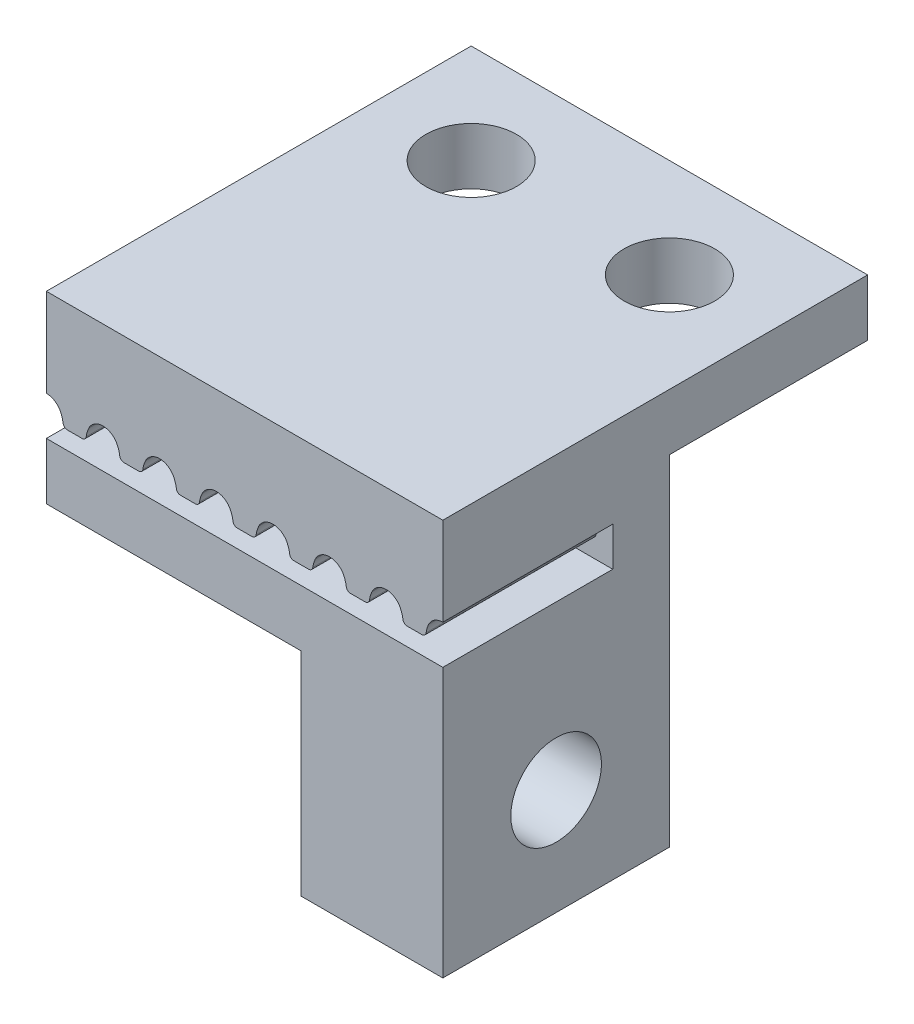
from build123d import *

# Parameters (mm, degrees)
SKETCH3_W           = 14
SKETCH3_H           = 6.5
BOSS_EXTRUDE2_DEPTH = 8
CUT_EXTRUDE1_START  = 2
CUT_EXTRUDE1_DEPTH  = 6
LPATTERN2_COUNT     = 7
LPATTERN2_PITCH     = 2
SKETCH4_W           = 14
SKETCH4_H           = 7
SKETCH4_R           = 1.6
BOSS_EXTRUDE3_DEPTH = 2
SKETCH5_W           = 5
SKETCH5_H           = 8
BOSS_EXTRUDE4_DEPTH = 7.5
SKETCH6_R           = 1.6
CUT_EXTRUDE2_DEPTH  = 7.5


with BuildPart() as part:
    # Sketch3 → Boss-Extrude2 (new body)
    with BuildSketch(Plane.XY):
        with Locations((7, 1.25)):
            Rectangle(SKETCH3_W, SKETCH3_H)
    extrude(amount=BOSS_EXTRUDE2_DEPTH)

    # Sketch1 → Cut-Extrude1 (cut)
    with BuildSketch(Plane.XY.offset(CUT_EXTRUDE1_START)):
        with BuildLine():
            Line((0.740175425, 0.63), (1.259824575, 0.63))
            ThreePointArc((1.259824575, 0.63), (1.358731646, 0.667228588), (1.408543109, 0.760434783))
            ThreePointArc((1.408543109, 0.760434783), (1.442388286, 0.918062154), (1.501123596, 1.068202247))
            ThreePointArc((1.501123596, 1.068202247), (1.705850588, 1.295639059), (2, 1.38))
            Line((2, 1.38), (2, 0))
            Line((2, 0), (0, 0))
            Line((0, 0), (0, 1.38))
            ThreePointArc((0, 1.38), (0.294149412, 1.295639059), (0.498876404, 1.068202247))
            ThreePointArc((0.498876404, 1.068202247), (0.557611714, 0.918062154), (0.591456891, 0.760434783))
            ThreePointArc((0.591456891, 0.760434783), (0.641268354, 0.667228588), (0.740175425, 0.63))
        make_face()
    cut_extrude1 = extrude(amount=CUT_EXTRUDE1_DEPTH, mode=Mode.SUBTRACT)

    # LPattern2: Cut-Extrude1 ×7
    with Locations(*[(i * LPATTERN2_PITCH, 0, 0) for i in range(1, LPATTERN2_COUNT)]):
        add(cut_extrude1, mode=Mode.SUBTRACT)

    # Sketch4 → Boss-Extrude3 (add)
    with BuildSketch(Plane(origin=(0, 4.5, 0), x_dir=(-1, 0, 0), z_dir=(0, 1, 0))):
        with Locations((-7, -3.5)):
            Rectangle(SKETCH4_W, SKETCH4_H)
        with Locations((-10.5, -3.5)):
            Circle(SKETCH4_R, mode=Mode.SUBTRACT)
        with Locations((-3.5, -3.5)):
            Circle(SKETCH4_R, mode=Mode.SUBTRACT)
    extrude(amount=-BOSS_EXTRUDE3_DEPTH)

    # Sketch5 → Boss-Extrude4 (add)
    with BuildSketch(Plane.XZ.offset(2)):
        with Locations((11.5, 4)):
            Rectangle(SKETCH5_W, SKETCH5_H)
    extrude(amount=BOSS_EXTRUDE4_DEPTH)

    # Sketch6 → Cut-Extrude2 (cut)
    with BuildSketch(Plane.ZY.offset(-9)):
        with Locations((4, -5.75)):
            Circle(SKETCH6_R)
    extrude(amount=-CUT_EXTRUDE2_DEPTH, mode=Mode.SUBTRACT)


solid = part.part
